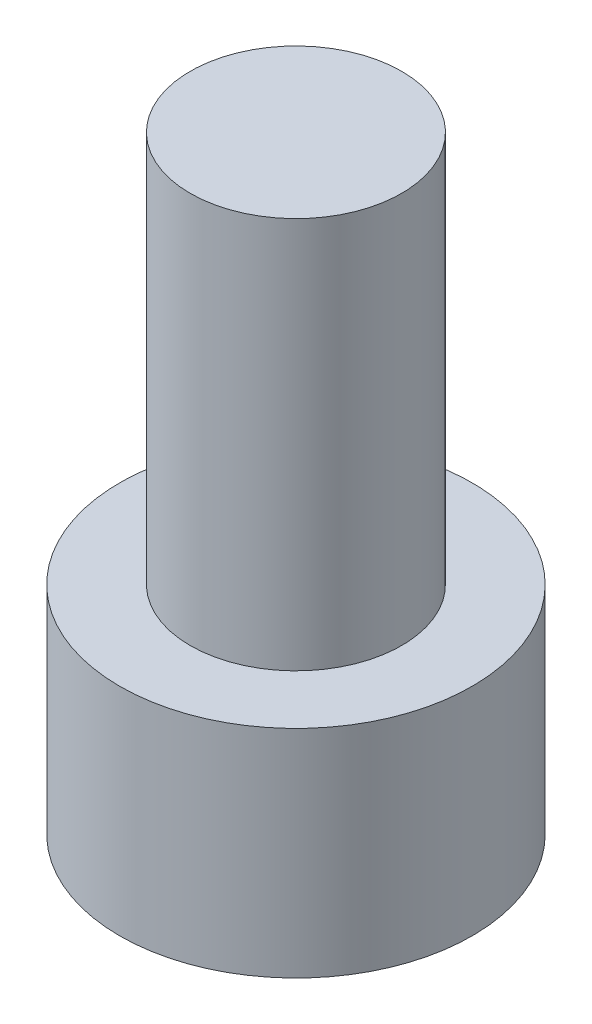
from build123d import *

# Parameters (mm, degrees)
SKETCH1_R           = 2.8575
BOSS_EXTRUDE1_DEPTH = 3.5052
CUT_EXTRUDE1_DEPTH  = 1.9558
SKETCH3_R           = 1.7145
BOSS_EXTRUDE2_DEPTH = 6.35


with BuildPart() as part:
    # Sketch1 → Boss-Extrude1 (new body)
    with BuildSketch(Plane(origin=(0, 0, 0), x_dir=(1, 0, 0), z_dir=(0, 1, 0))):
        Circle(SKETCH1_R)
    extrude(amount=BOSS_EXTRUDE1_DEPTH)

    # Sketch2 → Cut-Extrude1 (cut)
    with BuildSketch(Plane.XZ):
        Polygon((1.603951217, 0), (0.801975608, 1.3890625), (-0.801975608, 1.3890625), (-1.603951217, 0), (-0.801975608, -1.3890625), (0.801975608, -1.3890625), align=None)
    extrude(amount=-CUT_EXTRUDE1_DEPTH, mode=Mode.SUBTRACT)

    # Sketch3 → Boss-Extrude2 (add)
    with BuildSketch(Plane(origin=(0, 3.5052, 0), x_dir=(1, 0, 0), z_dir=(0, 1, 0))):
        Circle(SKETCH3_R)
    extrude(amount=BOSS_EXTRUDE2_DEPTH)


solid = part.part
